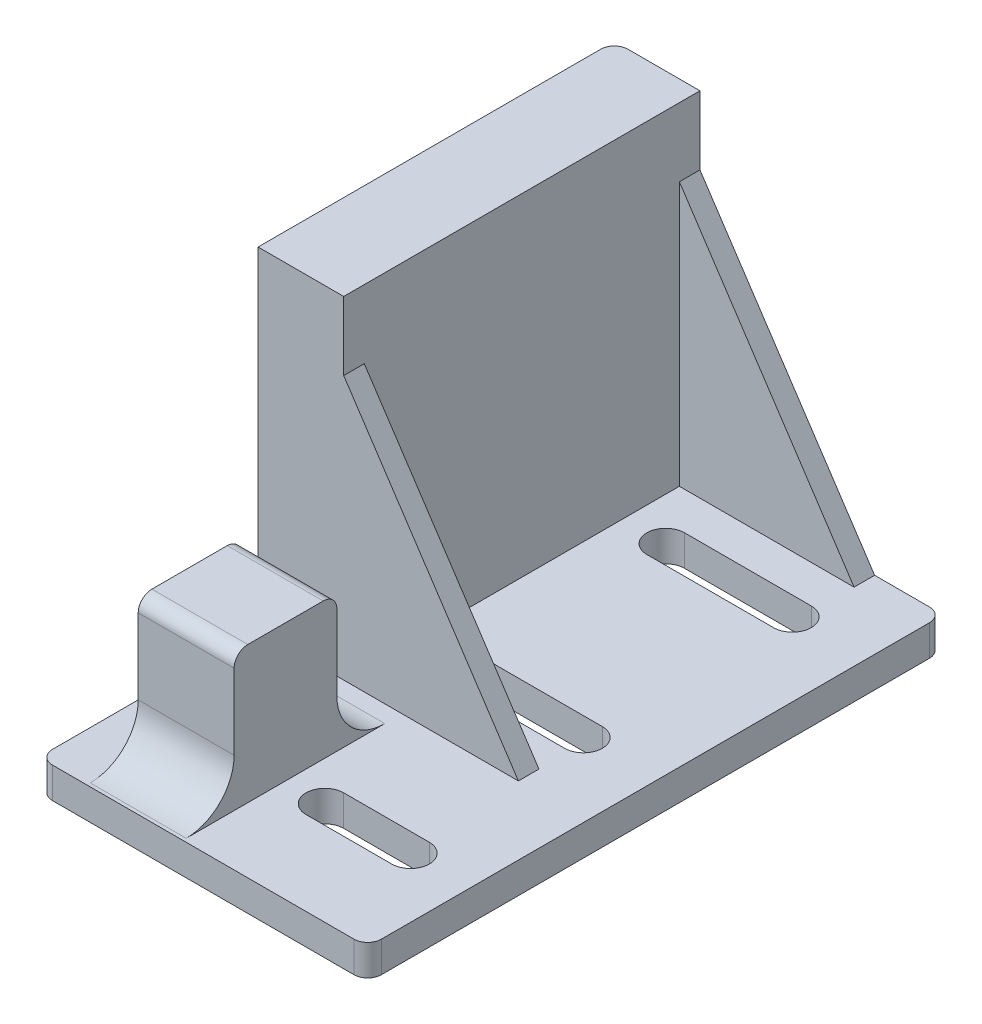
from build123d import *

# Parameters (mm, degrees)
SKETCH1_W           = 48
SKETCH1_H           = 84
BOSS_EXTRUDE1_DEPTH = 4.5
FILLET1_R           = 2
CUT_EXTRUDE1_DEPTH  = 49.582404222
BOSS_EXTRUDE2_DEPTH = 48.5
RIB1_REACH          = 104.181
SKETCH4_WALL_W      = 252.541422716
SKETCH4_WALL_H      = 3
RIB14_REACH         = 80.032
SKETCH5_WALL_W      = 204.243088956
SKETCH5_WALL_H      = 3
SKETCH6_R           = 11.1
CUT_EXTRUDE2_DEPTH  = 8
SKETCH7_W           = 14
SKETCH7_H           = 15
BOSS_EXTRUDE3_DEPTH = 20
FILLET2_R           = 7
FILLET3_R           = 2
SKETCH8_R           = 4
CUT_EXTRUDE3_DEPTH  = 10
CUT_EXTRUDE4_DEPTH  = 69.5


with BuildPart() as part:
    # Sketch1 → Boss-Extrude1 (new body)
    with BuildSketch(Plane(origin=(0, 0, 0), x_dir=(1, 0, 0), z_dir=(0, 1, 0))):
        Rectangle(SKETCH1_W, SKETCH1_H)
    extrude(amount=BOSS_EXTRUDE1_DEPTH)

    # Fillet1
    fillet1_edges = [part.edges().sort_by_distance(p)[0] for p in [
        (-24, 2.25, -42),
        (24, 2.25, -42),
        (24, 2.25, 42),
        (-24, 2.25, 42),
    ]]
    fillet(fillet1_edges, radius=FILLET1_R)

    # Sketch2 → Cut-Extrude1 (cut, through all)
    with BuildSketch(Plane(origin=(0, 4.5, 0), x_dir=(1, 0, 0), z_dir=(0, 1, 0))):
        with BuildLine():
            Line((-5.25, 33.5), (13.25, 33.5))
            ThreePointArc((13.25, 33.5), (16, 30.750000115), (13.25000023, 28))
            Line((13.25000023, 28), (-5.25, 28))
            ThreePointArc((-5.25, 28), (-8, 30.75), (-5.25, 33.5))
        make_face()
        with BuildLine():
            Line((-5.25, 3), (13.25000023, 3))
            ThreePointArc((13.25000023, 3), (16, 0.249999885), (13.25, -2.5))
            Line((13.25, -2.5), (-5.25, -2.5))
            ThreePointArc((-5.25, -2.5), (-8, 0.25), (-5.25, 3))
        make_face()
    extrude(amount=-CUT_EXTRUDE1_DEPTH, mode=Mode.SUBTRACT)

    # Sketch3 → Boss-Extrude2 (add)
    with BuildSketch(Plane(origin=(0, 4.5, 0), x_dir=(1, 0, 0), z_dir=(0, 1, 0))):
        with BuildLine():
            Line((-11.5, 42), (-22, 42))
            ThreePointArc((-22, 42), (-23.414213562, 41.414213562), (-24, 40))
            Line((-24, 40), (-24, -10))
            Line((-24, -10), (-11.5, -10))
            Line((-11.5, -10), (-11.5, 42))
        make_face()
    extrude(amount=BOSS_EXTRUDE2_DEPTH)

    # Sketch4 wall → Rib1 (add, up to next)
    with BuildSketch(Plane(origin=(1.25, 23.75, -42), x_dir=(-0.552199056825, 0.833712301481, 0), z_dir=(0.833712301481, 0.552199056825, 0)), mode=Mode.PRIVATE) as rib1_sk1:
        with Locations((0, 1.5)):
            Rectangle(SKETCH4_WALL_W, SKETCH4_WALL_H)
    rib1_tool1 = extrude(rib1_sk1.sketch, amount=-RIB1_REACH, mode=Mode.PRIVATE) - part.part
    add(rib1_tool1.solids().sort_by_distance((1.25, 23.75, -42))[0])

    # Sketch5 wall → Rib14 (add, up to next)
    with BuildSketch(Plane(origin=(1.25, 23.75, 10), x_dir=(-0.552199056825, 0.833712301481, 0), z_dir=(-0.833712301481, -0.552199056825, 0)), mode=Mode.PRIVATE) as rib14_sk1:
        with Locations((0, 1.5)):
            Rectangle(SKETCH5_WALL_W, SKETCH5_WALL_H)
    rib14_tool1 = extrude(rib14_sk1.sketch, amount=RIB14_REACH, mode=Mode.PRIVATE) - part.part
    add(rib14_tool1.solids().sort_by_distance((1.25, 23.75, 10))[0])

    # Sketch6 → Cut-Extrude2 (cut)
    with BuildSketch(Plane.ZY.offset(24)):
        with Locations((-16, 25.65)):
            Circle(SKETCH6_R)
    extrude(amount=-CUT_EXTRUDE2_DEPTH, mode=Mode.SUBTRACT)

    # Sketch7 → Boss-Extrude3 (add)
    with BuildSketch(Plane(origin=(0, 4.5, 0), x_dir=(1, 0, 0), z_dir=(0, 1, 0))):
        with Locations((-10, -27)):
            Rectangle(SKETCH7_W, SKETCH7_H)
    extrude(amount=BOSS_EXTRUDE3_DEPTH)

    # Fillet2
    fillet2_edges = [part.edges().sort_by_distance(p)[0] for p in [
        (-10, 4.5, 34.5),
        (-10, 4.5, 19.5),
    ]]
    fillet(fillet2_edges, radius=FILLET2_R)

    # Fillet3
    fillet3_edges = [part.edges().sort_by_distance(p)[0] for p in [
        (-10, 24.5, 34.5),
        (-10, 24.5, 19.5),
    ]]
    fillet(fillet3_edges, radius=FILLET3_R)

    # Sketch8 → Cut-Extrude3 (cut)
    with BuildSketch(Plane.ZY.offset(17)):
        with Locations((27, 16.5)):
            Circle(SKETCH8_R)
    extrude(amount=-CUT_EXTRUDE3_DEPTH, mode=Mode.SUBTRACT)

    # Sketch9 → Cut-Extrude4 (cut, through all)
    with BuildSketch(Plane(origin=(0, 4.5, 0), x_dir=(1, 0, 0), z_dir=(0, 1, 0))):
        with BuildLine():
            Line((2.75, -24.25), (15.25, -24.25))
            ThreePointArc((15.25, -24.25), (18, -27), (15.25, -29.75))
            Line((15.25, -29.75), (2.75, -29.75))
            ThreePointArc((2.75, -29.75), (0, -27), (2.75, -24.25))
        make_face()
    extrude(amount=-CUT_EXTRUDE4_DEPTH, mode=Mode.SUBTRACT)


solid = part.part
